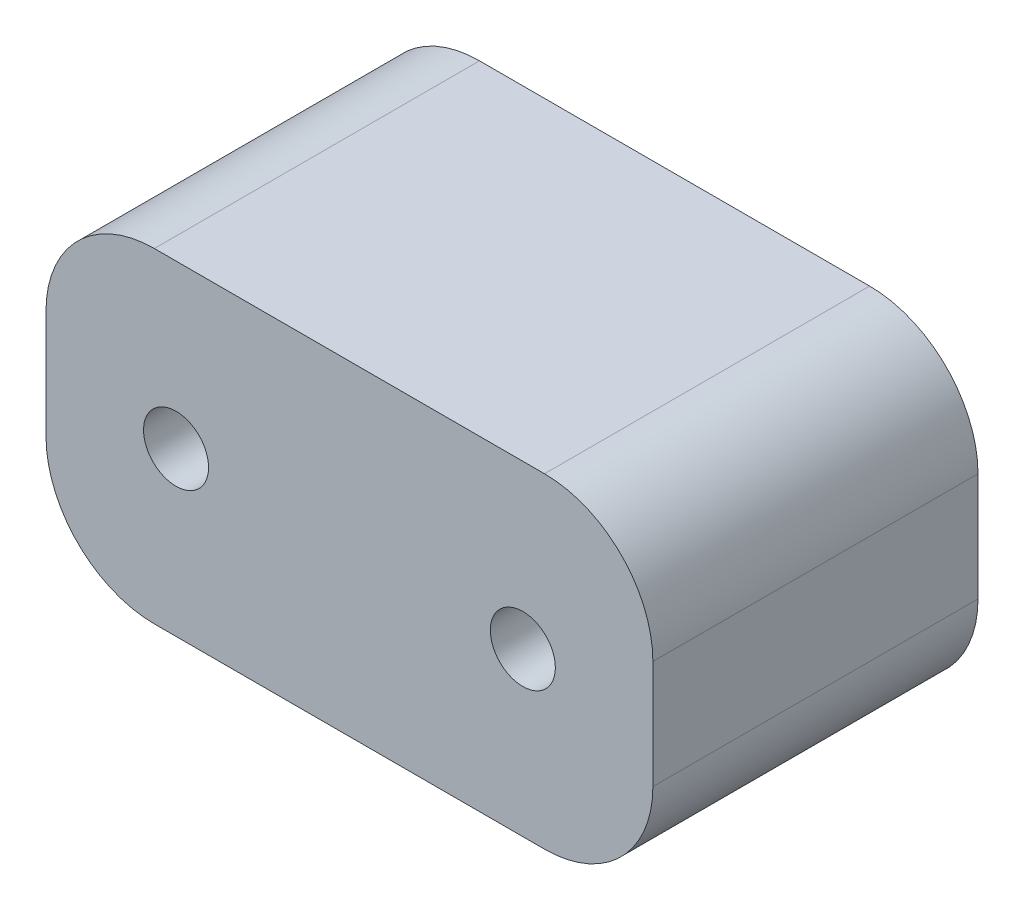
from build123d import *

# Parameters (mm, degrees)
ESBO_O1_W                = 28
ESBO_O1_H                = 15
ESBO_O1_R                = 1.5
RESSALTO_EXTRUS_O1_DEPTH = 15
FILETE1_R                = 5


with BuildPart() as part:
    # Esboço1 → Ressalto-extrusão1 (new body)
    with BuildSketch(Plane.XY):
        Rectangle(ESBO_O1_W, ESBO_O1_H)
        with Locations((-8, 0)):
            Circle(ESBO_O1_R, mode=Mode.SUBTRACT)
        with Locations((8, 0)):
            Circle(ESBO_O1_R, mode=Mode.SUBTRACT)
    extrude(amount=RESSALTO_EXTRUS_O1_DEPTH)

    # Filete1
    filete1_edges = [part.edges().sort_by_distance(p)[0] for p in [
        (14, -7.5, 7.5),
        (-14, -7.5, 7.5),
        (-14, 7.5, 7.5),
        (14, 7.5, 7.5),
    ]]
    fillet(filete1_edges, radius=FILETE1_R)


solid = part.part
